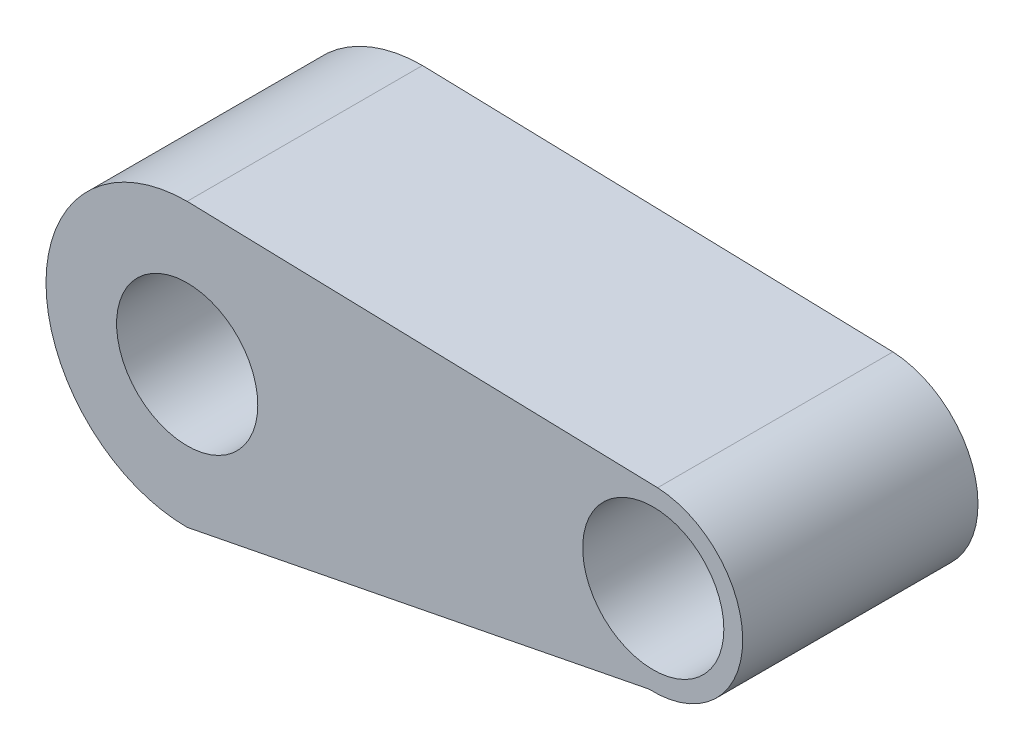
from build123d import *

# Parameters (mm, degrees)
SKETCH1_R           = 1.5
BOSS_EXTRUDE1_DEPTH = 5


with BuildPart() as part:
    # Sketch1 → Boss-Extrude1 (new body)
    with BuildSketch(Plane.XY):
        with BuildLine():
            ThreePointArc((0, 3), (-3, 0), (0, -3))
            Line((0, -3), (9.811944565, -1.069781397))
            ThreePointArc((9.811944565, -1.069781397), (11.802791902, 0.736722114), (9.996288391, 2.727569451))
            Line((9.996288391, 2.727569451), (0, 3))
        make_face()
        Circle(SKETCH1_R, mode=Mode.SUBTRACT)
        with Locations((9.904116478, 0.828894027)):
            Circle(SKETCH1_R, mode=Mode.SUBTRACT)
    extrude(amount=BOSS_EXTRUDE1_DEPTH)


solid = part.part
